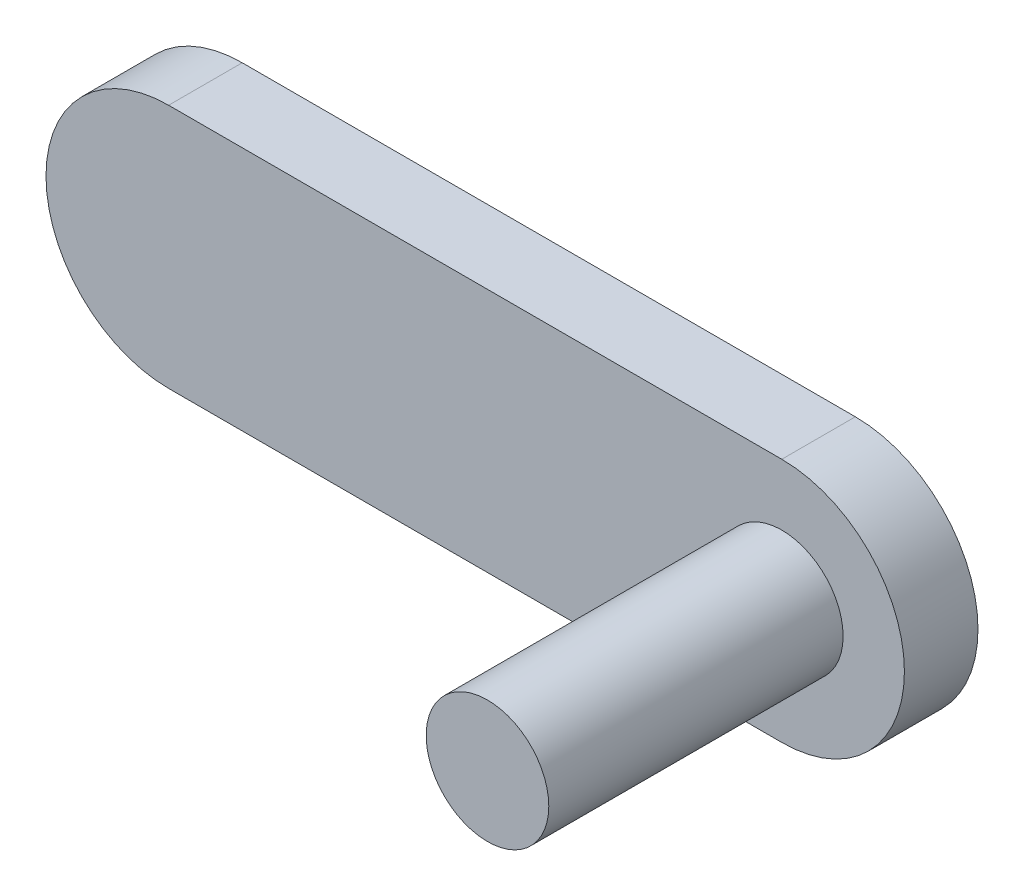
from build123d import *

# Parameters (mm, degrees)
EXTRUDE_1_DEPTH = 3
SKETCH_1_4_R    = 2.5
EXTRUDE_3_DEPTH = 15


with BuildPart() as part:
    # 草圖1 → 填料-伸長1 (new body)
    with BuildSketch(Plane.XY):
        with BuildLine():
            Line((25, 5), (0, 5))
            ThreePointArc((0, 5), (-5, 0), (0, -5))
            Line((0, -5), (25, -5))
            ThreePointArc((25, -5), (30, 0), (25, 5))
        make_face()
    extrude(amount=EXTRUDE_1_DEPTH)

    # 草圖1<4> → 填料-伸長3 (add)
    with BuildSketch(Plane.XY):
        with Locations((25, 0)):
            Circle(SKETCH_1_4_R)
    extrude(amount=EXTRUDE_3_DEPTH)


solid = part.part
